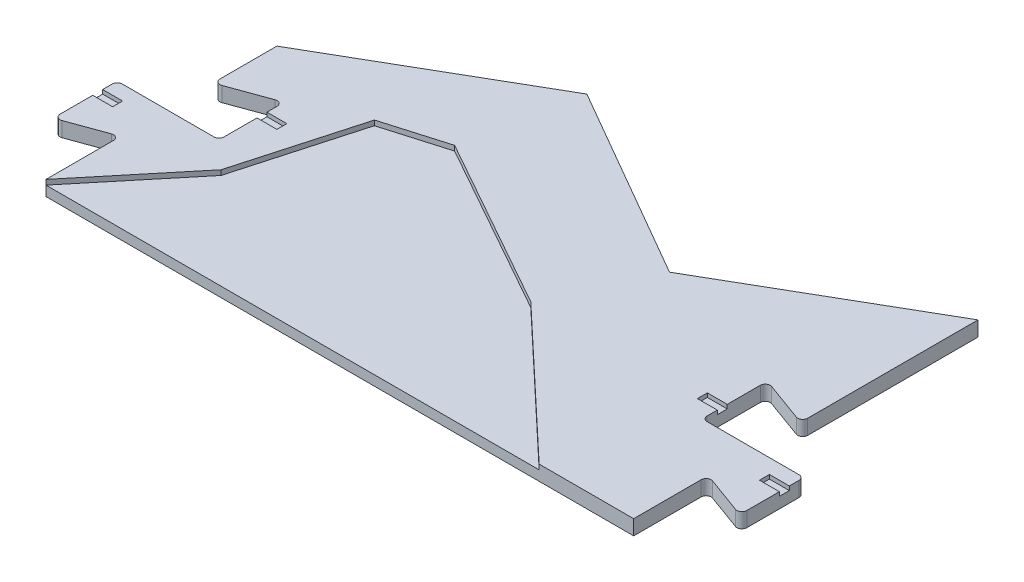
from build123d import *

# Parameters (mm, degrees)
P_IDAT_VYSUNUT_M1_DEPTH  = 3
P_IDAT_VYSUNUT_M2_DEPTH  = 2
ZAOBLIT3_R               = 1
SKICA2_W                 = 4
SKICA2_H                 = 2
ODEBRAT_VYSUNUT_M1_DEPTH = 0.8
SKICA3_W                 = 4
SKICA3_H                 = 2
ODEBRAT_VYSUNUT_M2_DEPTH = 0.8


with BuildPart() as part:
    # Skica1 → P_idat vysunut_m1 (new body)
    with BuildSketch(Plane(origin=(0, 0, 0), x_dir=(1, 0, 0), z_dir=(0, 1, 0))):
        Polygon((-118.143750166, 15), (-118.143750166, 0), (-102.227105248, 19.278496169), (-95.473037065, 43.348863075), (-82.997228437, 47.003202833), (-48.112980408, 27.430537213), (-19, 0), (0, 0), (0, 15), (9.950504516, 11.37831254), (9.950504516, 24.27831254), (-10.5, 24.27831254), (-10.5, 37.37831254), (0, 33.55662508), (0, 69.224902673), (-39.317553332, 46.524902673), (-78.635106664, 69.224902673), (-118.143185584, 46.414902673), (-118.143185584, 33.5570142), (-107.643750166, 37.378496169), (-107.643750166, 24.278496169), (-128.093750166, 24.278496169), (-128.093750166, 11.378496169), align=None)
    extrude(amount=P_IDAT_VYSUNUT_M1_DEPTH)

    # Skica1_3 → P_idat vysunut_m2 (add)
    with BuildSketch(Plane(origin=(0, 0, 0), x_dir=(1, 0, 0), z_dir=(0, 1, 0))):
        Polygon((-102.227105248, 19.278496169), (-118.143750166, 0), (-19, 0), (-48.112980408, 27.430537213), (-82.997228437, 47.003202833), (-95.473037065, 43.348863075), align=None)
    extrude(amount=P_IDAT_VYSUNUT_M2_DEPTH)

    # Zaoblit3
    zaoblit3_edges = [part.edges().sort_by_distance(p)[0] for p in [
        (-107.643750166, 1.5, -24.278496169),
        (0, 1.5, -15),
        (9.950504516, 1.5, -11.37831254),
        (9.950504516, 1.5, -24.27831254),
        (-10.5, 1.5, -24.27831254),
        (-10.5, 1.5, -37.37831254),
        (0, 1.5, -33.55662508),
        (-118.143750166, 1.5, -15),
        (-128.093750166, 1.5, -11.378496169),
        (-128.093750166, 1.5, -24.278496169),
        (-107.643750166, 1.5, -37.378496169),
        (-118.143185584, 1.5, -33.5570142),
    ]]
    fillet(zaoblit3_edges, radius=ZAOBLIT3_R)

    # Skica2 → Odebrat vysunut_m1 (cut)
    with BuildSketch(Plane(origin=(0, 3, 0), x_dir=(1, 0, 0), z_dir=(0, 1, 0))):
        with Locations((-105.643750166, 32.914422166)):
            Rectangle(SKICA2_W, SKICA2_H)
        with Locations((-126.093750166, 20.342570172)):
            Rectangle(SKICA2_W, SKICA2_H)
    extrude(amount=-ODEBRAT_VYSUNUT_M1_DEPTH, mode=Mode.SUBTRACT)

    # Skica3 → Odebrat vysunut_m2 (cut)
    with BuildSketch(Plane(origin=(0, 3, 0), x_dir=(1, 0, 0), z_dir=(0, 1, 0))):
        with Locations((-12.5, 28.314238537)):
            Rectangle(SKICA3_W, SKICA3_H)
        with Locations((7.950504516, 20.342386544)):
            Rectangle(SKICA3_W, SKICA3_H)
    extrude(amount=-ODEBRAT_VYSUNUT_M2_DEPTH, mode=Mode.SUBTRACT)


solid = part.part
